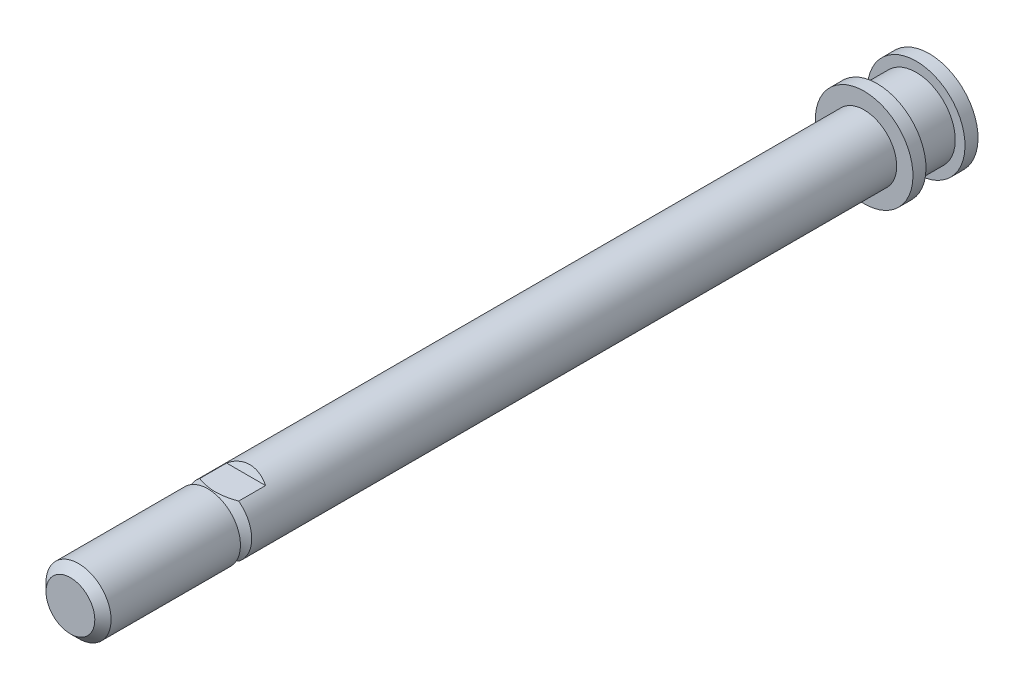
from build123d import *

# Parameters (mm, degrees)
SMUSSO1_SIZE                  = 1.25
TAGLIO_ESTRUSIONE1_DEPTH      = 111.510180527
TAGLIO_ESTRUSIONE1_DEPTH_BACK = 111.510180527


with BuildPart() as part:
    # Schizzo1 → Rivoluzione1 (revolve)
    with BuildSketch(Plane(origin=(0, 0, 0), x_dir=(0, 0, -1), z_dir=(1, 0, 0))):
        Polygon((0, 0), (-22, 0), (-22, 5), (-0.866025404, 5), (0, 3.5), (0.866025404, 5), (100, 5), (100, 7.5), (102, 7.5), (102, 6), (108, 6), (108, 7.5), (110, 7.5), (110, 0), align=None)
    revolve(axis=Axis((0, 0, 22), (0, 0, 1)))

    # Smusso1
    smusso1_edges = [part.edges().sort_by_distance(p)[0] for p in [
        (0, -5, 22),
    ]]
    chamfer(smusso1_edges, length=SMUSSO1_SIZE)

    # Schizzo2 → Taglio-Estrusione1 (cut, two sides: drawn at the far end of the back side and taken through both)
    with BuildSketch(Plane(origin=(0, 0, 0), x_dir=(0, 0, -1), z_dir=(1, 0, 0)).offset(-TAGLIO_ESTRUSIONE1_DEPTH_BACK)):
        Polygon((5.577350269, 5), (0, 5), (0, 4), (5, 4), align=None)
        Polygon((0, -5), (0, -4), (5, -4), (5.577350269, -5), align=None)
    extrude(amount=TAGLIO_ESTRUSIONE1_DEPTH + TAGLIO_ESTRUSIONE1_DEPTH_BACK, mode=Mode.SUBTRACT)


solid = part.part
